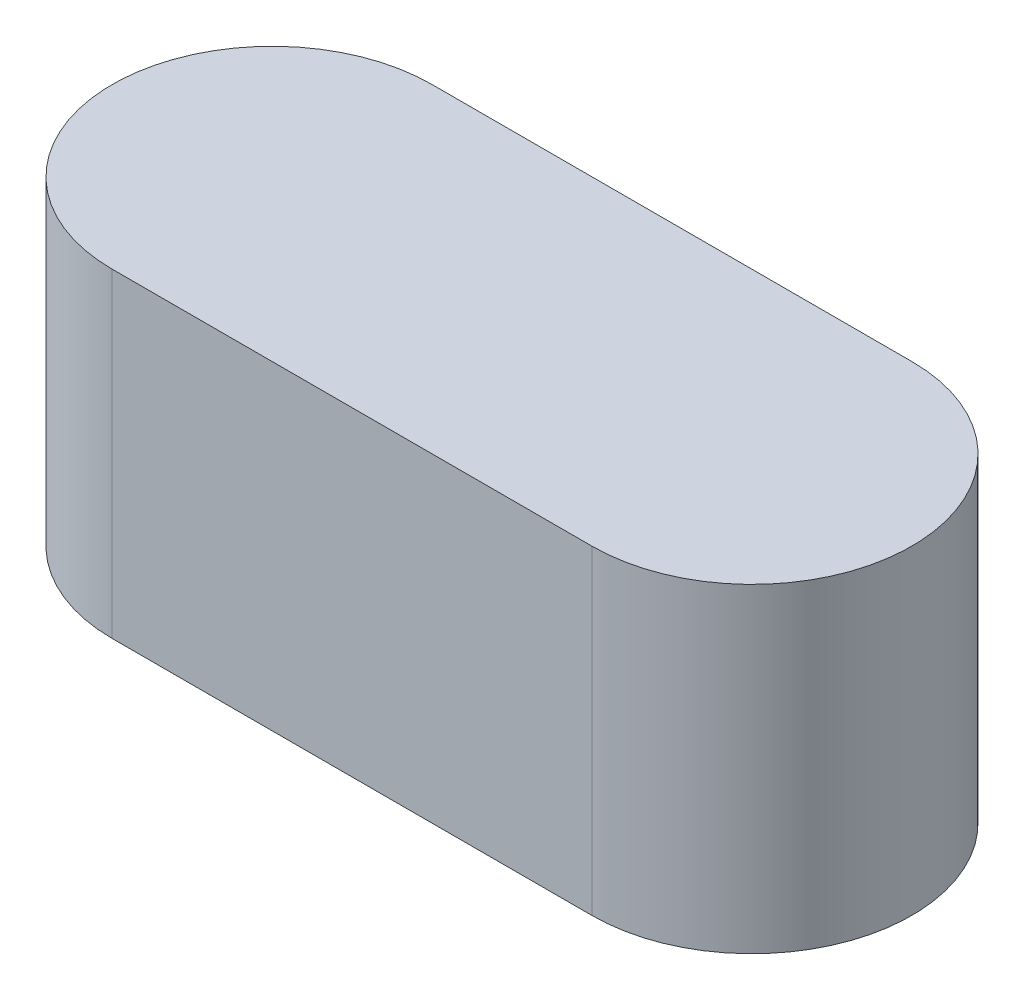
from build123d import *

# Parameters (mm, degrees)
SKETCH_1_R      = 10
EXTRUDE_1_DEPTH = 20
EXTRUDE_2_DEPTH = 20


with BuildPart() as part:
    # 草图1 → 凸台-拉伸1 (new body)
    with BuildSketch(Plane(origin=(0, 0, 0), x_dir=(1, 0, 0), z_dir=(0, 1, 0))):
        Circle(SKETCH_1_R)
    extrude(amount=EXTRUDE_1_DEPTH)

    # 草图2 → 凸台-拉伸2 (add)
    with BuildSketch(Plane(origin=(0, 20, 0), x_dir=(1, 0, 0), z_dir=(0, 1, 0))):
        with BuildLine():
            Line((0, 10), (30, 10))
            ThreePointArc((30, 10), (40, 0), (30, -10))
            Line((30, -10), (0, -10))
            Line((0, -10), (0, 10))
        make_face()
    extrude(amount=-EXTRUDE_2_DEPTH)


solid = part.part
